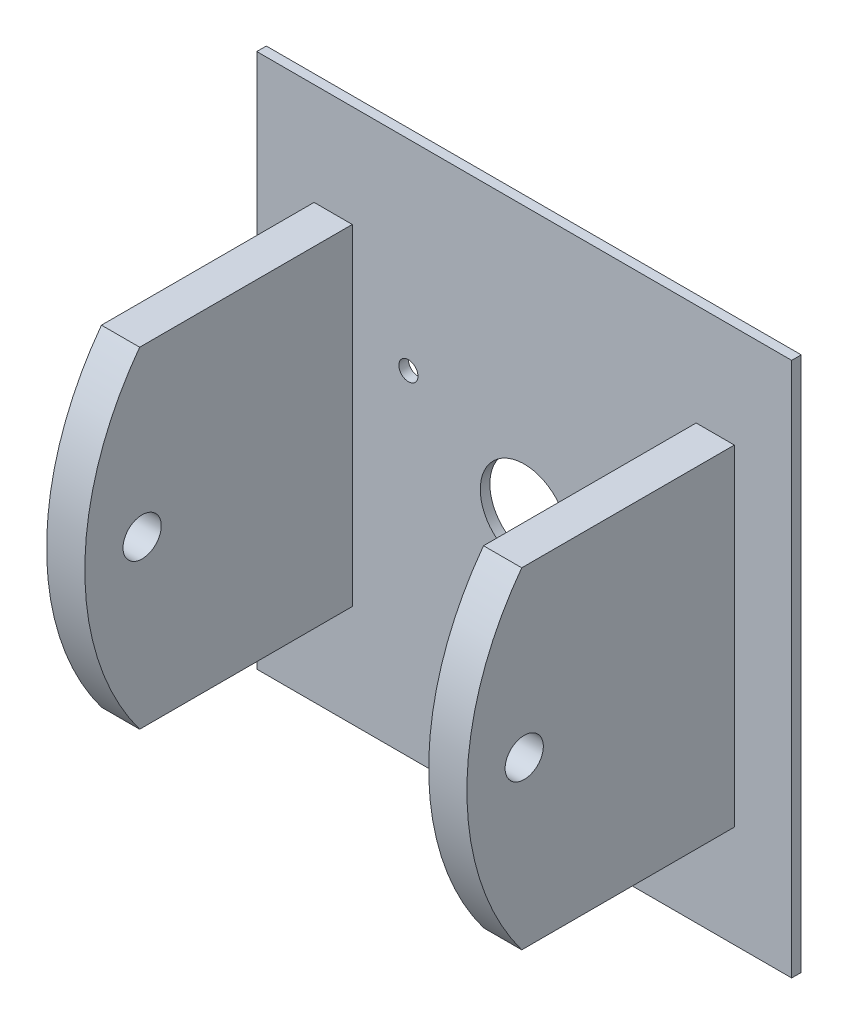
from build123d import *

# Parameters (mm, degrees)
SKETCH1_W           = 177.8
SKETCH1_H           = 177.8
SKETCH1_R           = 14.605
BOSS_EXTRUDE1_DEPTH = 3.175
SKETCH2_R           = 3.175
CUT_EXTRUDE1_DEPTH  = 126.763669734
SKETCH2_3_W         = 12.7
SKETCH2_3_H         = 109.98522628
BOSS_EXTRUDE2_DEPTH = 88.9
SKETCH3_R           = 6.35
CUT_EXTRUDE2_DEPTH  = 204.918067186


with BuildPart() as part:
    # Sketch1 → Boss-Extrude1 (new body)
    with BuildSketch(Plane.XY):
        Rectangle(SKETCH1_W, SKETCH1_H)
        Circle(SKETCH1_R, mode=Mode.SUBTRACT)
    extrude(amount=BOSS_EXTRUDE1_DEPTH)

    # Sketch2 → Cut-Extrude1 (cut, through all)
    with BuildSketch(Plane.XY.offset(3.175)):
        with Locations((-38.494829198, 22.225)):
            Circle(SKETCH2_R)
        with Locations((0, -44.45)):
            Circle(SKETCH2_R)
        with Locations((38.494829198, 22.225)):
            Circle(SKETCH2_R)
    extrude(amount=-CUT_EXTRUDE1_DEPTH, mode=Mode.SUBTRACT)

    # Sketch2_3 → Boss-Extrude2 (add)
    with BuildSketch(Plane.XY.offset(3.175)):
        with Locations((-63.5, 0)):
            Rectangle(SKETCH2_3_W, SKETCH2_3_H)
        with Locations((63.5, 0)):
            Rectangle(SKETCH2_3_W, SKETCH2_3_H)
    extrude(amount=BOSS_EXTRUDE2_DEPTH)

    # Sketch3 → Cut-Extrude2 (cut, through all)
    with BuildSketch(Plane.ZY.offset(69.85)):
        with Locations((73.025, 0)):
            Circle(SKETCH3_R)
        with BuildLine():
            ThreePointArc((73.84861627, 54.99261314), (87.399705286, 28.967173507), (92.075, 0))
            Line((92.075, 0), (92.075, 54.99261314))
            Line((92.075, 54.99261314), (73.84861627, 54.99261314))
        make_face()
        with BuildLine():
            Line((92.075, -54.99261314), (92.075, 0))
            ThreePointArc((92.075, 0), (87.399705286, -28.967173507), (73.84861627, -54.99261314))
            Line((73.84861627, -54.99261314), (92.075, -54.99261314))
        make_face()
    extrude(amount=-CUT_EXTRUDE2_DEPTH, mode=Mode.SUBTRACT)


solid = part.part
